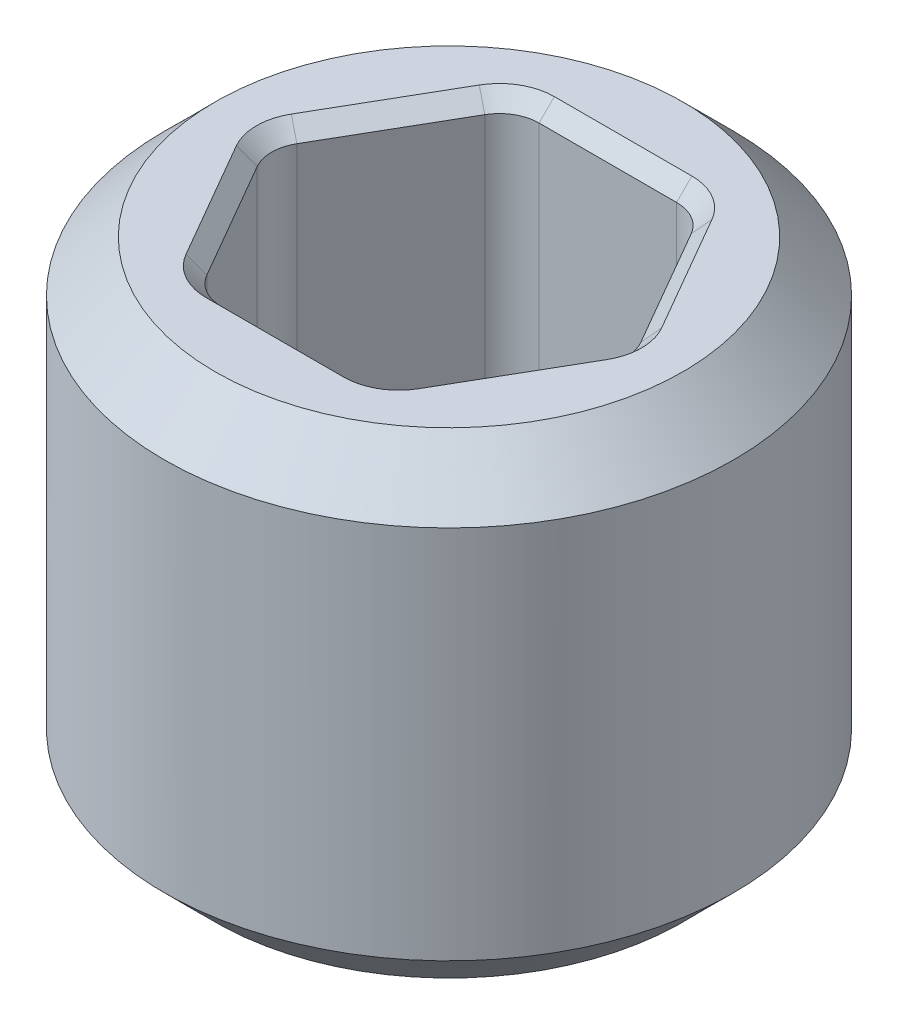
from build123d import *

# Parameters (mm, degrees)
SKETCH1_W               = 1.4224
SKETCH1_H               = 2.38125
CUT_EXTRUDE1_DEPTH      = 2.190625
CUT_EXTRUDE1_DEPTH_BACK = 2.190625
FILLET1_R               = 0.1984375
CHAMFER1_SIZE           = 0.254
CHAMFER2_SIZE           = 0.0762


with BuildPart() as part:
    # Sketch1 → Revolve1 (revolve)
    with BuildSketch(Plane.XY):
        with Locations((0.7112, 0)):
            Rectangle(SKETCH1_W, SKETCH1_H)
    revolve(axis=Axis((0, -1.704166029, 0), (0, 1, 0)))

    # Sketch3 → Cut-Extrude1 (cut, two sides)
    with BuildSketch(Plane(origin=(0, 0, 0), x_dir=(1, 0, 0), z_dir=(0, 1, 0))) as cut_extrude1_sk:
        Polygon((0.916543552, 0), (0.458271776, 0.79375), (-0.458271776, 0.79375), (-0.916543552, 0), (-0.458271776, -0.79375), (0.458271776, -0.79375), align=None)
    extrude(amount=CUT_EXTRUDE1_DEPTH, mode=Mode.SUBTRACT)
    extrude(cut_extrude1_sk.sketch, amount=-CUT_EXTRUDE1_DEPTH_BACK, mode=Mode.SUBTRACT)

    # Fillet1
    fillet1_edges = [part.edges().sort_by_distance(p)[0] for p in [
        (0.458271776, 0, -0.79375),
        (0.916543552, 0, 0),
        (0.458271776, 0, 0.79375),
        (-0.458271776, 0, 0.79375),
        (-0.916543552, 0, 0),
        (-0.458271776, 0, -0.79375),
    ]]
    fillet(fillet1_edges, radius=FILLET1_R)

    # Chamfer1
    chamfer1_edges = [part.edges().sort_by_distance(p)[0] for p in [
        (-1.4224, 1.190625, 0),
        (-1.4224, -1.190625, 0),
    ]]
    chamfer(chamfer1_edges, length=CHAMFER1_SIZE)

    # Chamfer2
    chamfer2_edges = [part.edges().sort_by_distance(p)[0] for p in [
        (0.687407664, -1.190625, -0.396875),
        (0.687407664, 1.190625, -0.396875),
        (0.687407664, -1.190625, 0.396875),
        (0.687407664, 1.190625, 0.396875),
        (0, -1.190625, 0.79375),
        (0, 1.190625, 0.79375),
        (-0.687407664, -1.190625, 0.396875),
        (-0.687407664, 1.190625, 0.396875),
        (-0.687407664, -1.190625, -0.396875),
        (-0.687407664, 1.190625, -0.396875),
        (0, -1.190625, -0.79375),
        (0, 1.190625, -0.79375),
        (0.885845164, 1.190625, 0),
        (0.885845164, -1.190625, 0),
        (0.442922582, 1.190625, 0.767164416),
        (0.442922582, -1.190625, 0.767164416),
        (-0.442922582, 1.190625, 0.767164416),
        (-0.442922582, -1.190625, 0.767164416),
        (-0.885845164, 1.190625, 0),
        (-0.885845164, -1.190625, 0),
        (-0.442922582, 1.190625, -0.767164416),
        (-0.442922582, -1.190625, -0.767164416),
        (0.442922582, 1.190625, -0.767164416),
        (0.442922582, -1.190625, -0.767164416),
    ]]
    chamfer(chamfer2_edges, length=CHAMFER2_SIZE)


solid = part.part
